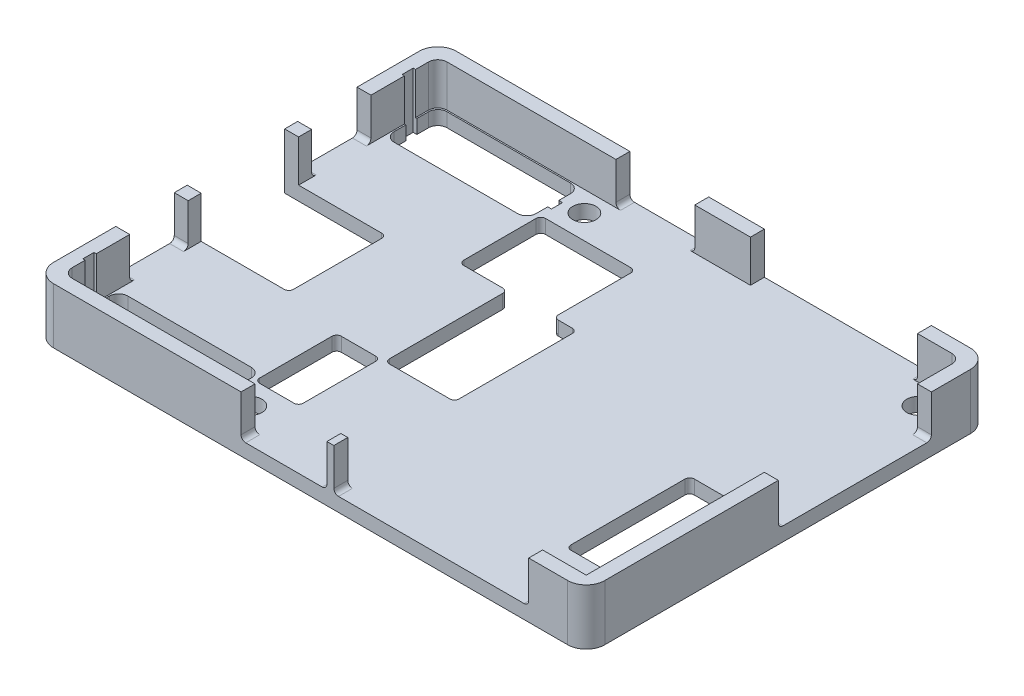
from build123d import *

# Parameters (mm, degrees)
SKETCH_1_W               = 59.4
SKETCH_1_H               = 43.4
EXTRUDE_1_DEPTH          = 6
SKETCH_2_W               = 56.4
SKETCH_2_H               = 40.4
CUT_EXTRUDE_1_DEPTH      = 4.5
SKETCH_3_R               = 1.25
CUT_EXTRUDE_2_DEPTH      = 2.5
SKETCH_4_W               = 10.95
SKETCH_4_H               = 10.5
CUT_EXTRUDE_3_DEPTH      = 5.5
CUT_EXTRUDE_3_DEPTH_BACK = 2.5
SKETCH_5_W               = 6.4
SKETCH_5_H               = 4.5
SKETCH_5_W_2             = 6.3
CUT_EXTRUDE_4_DEPTH      = 4.5
CUT_EXTRUDE_5_DEPTH      = 5.5
CUT_EXTRUDE_5_DEPTH_BACK = 2.5
SKETCH_9_W               = 10.2
SKETCH_9_H               = 8.8
SKETCH_9_W_2             = 4.7
CUT_EXTRUDE_6_DEPTH      = 5.5
CUT_EXTRUDE_6_DEPTH_BACK = 2.5
SKETCH_10_W              = 8
SKETCH_10_H              = 13.3
CUT_EXTRUDE_7_DEPTH      = 5.5
CUT_EXTRUDE_7_DEPTH_BACK = 2.5
FILLET_1_R               = 2
SKETCH_11_W              = 8.5
SKETCH_11_H              = 4.5
SKETCH_11_W_2            = 18
CUT_EXTRUDE_8_DEPTH      = 3
SKETCH_12_W              = 9.25
SKETCH_12_H              = 4.5
SKETCH_12_W_2            = 21
CUT_EXTRUDE_9_DEPTH      = 3
SKETCH_13_W              = 16.5
SKETCH_13_H              = 4.5
CUT_EXTRUDE_10_DEPTH     = 3
SKETCH_14_W              = 7.5
SKETCH_14_H              = 13.2
CUT_EXTRUDE_11_DEPTH     = 10
FILLET_2_R               = 0.5
FILLET_3_R               = 1
FILLET_4_R               = 0.5


with BuildPart() as part:
    # 草图1 → 凸台-拉伸1 (new body)
    with BuildSketch(Plane(origin=(0, 0, 0), x_dir=(1, 0, 0), z_dir=(0, 1, 0))):
        Rectangle(SKETCH_1_W, SKETCH_1_H)
    extrude(amount=EXTRUDE_1_DEPTH)

    # 草图2 → 切除-拉伸1 (cut)
    with BuildSketch(Plane(origin=(0, 6, 0), x_dir=(1, 0, 0), z_dir=(0, 1, 0))):
        Rectangle(SKETCH_2_W, SKETCH_2_H)
    extrude(amount=-CUT_EXTRUDE_1_DEPTH, mode=Mode.SUBTRACT)

    # 草图3 → 切除-拉伸2 (cut, through all)
    with BuildSketch(Plane(origin=(0, 1.5, 0), x_dir=(1, 0, 0), z_dir=(0, 1, 0))):
        with Locations((-10.2, -18)):
            Circle(SKETCH_3_R)
        with Locations((-10.2, 18)):
            Circle(SKETCH_3_R)
        with Locations((25.8, 18)):
            Circle(SKETCH_3_R)
        with Locations((25.8, -18)):
            Circle(SKETCH_3_R)
    extrude(amount=-CUT_EXTRUDE_2_DEPTH, mode=Mode.SUBTRACT)

    # 草图4 → 切除-拉伸3 (cut, two sides)
    with BuildSketch(Plane(origin=(0, 1.5, 0), x_dir=(1, 0, 0), z_dir=(0, 1, 0))) as cut_extrude_3_sk:
        with Locations((-24.225, -0.05)):
            Rectangle(SKETCH_4_W, SKETCH_4_H)
    extrude(amount=CUT_EXTRUDE_3_DEPTH, mode=Mode.SUBTRACT)
    extrude(cut_extrude_3_sk.sketch, amount=-CUT_EXTRUDE_3_DEPTH_BACK, mode=Mode.SUBTRACT)

    # 草图5 → 切除-拉伸4 (cut)
    with BuildSketch(Plane.ZY.offset(29.7)):
        with Locations((-9.8, 3.75)):
            Rectangle(SKETCH_5_W, SKETCH_5_H)
        with Locations((9.85, 3.75)):
            Rectangle(SKETCH_5_W_2, SKETCH_5_H)
    extrude(amount=-CUT_EXTRUDE_4_DEPTH, mode=Mode.SUBTRACT)

    # 草图8 → 切除-拉伸5 (cut, two sides)
    with BuildSketch(Plane(origin=(0, 1.5, 0), x_dir=(1, 0, 0), z_dir=(0, 1, 0))) as cut_extrude_5_sk:
        Polygon((-28.05, 14.35), (-28.05, 16.6), (-28.45, 16.6), (-28.45, 17.8), (-28.05, 17.8), (-28.05, 20.05), (-12.75, 20.05), (-12.75, 17.8), (-12.35, 17.8), (-12.35, 16.6), (-12.75, 16.6), (-12.75, 14.35), align=None)
        Polygon((-28.05, -20.05), (-12.75, -20.05), (-12.75, -17.8), (-12.35, -17.8), (-12.35, -16.6), (-12.75, -16.6), (-12.75, -14.35), (-28.05, -14.35), (-28.05, -16.6), (-28.45, -16.6), (-28.45, -17.8), (-28.05, -17.8), align=None)
    extrude(amount=CUT_EXTRUDE_5_DEPTH, mode=Mode.SUBTRACT)
    extrude(cut_extrude_5_sk.sketch, amount=-CUT_EXTRUDE_5_DEPTH_BACK, mode=Mode.SUBTRACT)

    # 草图9 → 切除-拉伸6 (cut, two sides)
    with BuildSketch(Plane(origin=(0, 1.5, 0), x_dir=(1, 0, 0), z_dir=(0, 1, 0))) as cut_extrude_6_sk:
        with Locations((-7.2, 11)):
            Rectangle(SKETCH_9_W, SKETCH_9_H)
        with Locations((-9.95, -11)):
            Rectangle(SKETCH_9_W_2, SKETCH_9_H)
    extrude(amount=CUT_EXTRUDE_6_DEPTH, mode=Mode.SUBTRACT)
    extrude(cut_extrude_6_sk.sketch, amount=-CUT_EXTRUDE_6_DEPTH_BACK, mode=Mode.SUBTRACT)

    # 草图10 → 切除-拉伸7 (cut, two sides)
    with BuildSketch(Plane(origin=(0, 1.5, 0), x_dir=(1, 0, 0), z_dir=(0, 1, 0))) as cut_extrude_7_sk:
        with Locations((24.05, -7.55)):
            Rectangle(SKETCH_10_W, SKETCH_10_H)
    extrude(amount=CUT_EXTRUDE_7_DEPTH, mode=Mode.SUBTRACT)
    extrude(cut_extrude_7_sk.sketch, amount=-CUT_EXTRUDE_7_DEPTH_BACK, mode=Mode.SUBTRACT)

    # 圆角1
    fillet_1_edges = [part.edges().sort_by_distance(p)[0] for p in [
        (29.7, 3, 21.7),
        (-29.7, 3, 21.7),
        (-29.7, 3, -21.7),
        (29.7, 3, -21.7),
    ]]
    fillet(fillet_1_edges, radius=FILLET_1_R)

    # 草图11 → 切除-拉伸8 (cut)
    with BuildSketch(Plane(origin=(0, 0, -21.7), x_dir=(-1, 0, 0), z_dir=(0, 0, -1))):
        with Locations((4.75, 3.75)):
            Rectangle(SKETCH_11_W, SKETCH_11_H)
        with Locations((-14.5, 3.75)):
            Rectangle(SKETCH_11_W_2, SKETCH_11_H)
    extrude(amount=-CUT_EXTRUDE_8_DEPTH, mode=Mode.SUBTRACT)

    # 草图12 → 切除-拉伸9 (cut)
    with BuildSketch(Plane.XY.offset(21.7)):
        with Locations((-2.875, 3.75)):
            Rectangle(SKETCH_12_W, SKETCH_12_H)
        with Locations((13, 3.75)):
            Rectangle(SKETCH_12_W_2, SKETCH_12_H)
    extrude(amount=-CUT_EXTRUDE_9_DEPTH, mode=Mode.SUBTRACT)

    # 草图13 → 切除-拉伸10 (cut)
    with BuildSketch(Plane(origin=(29.7, 0, 0), x_dir=(0, 0, -1), z_dir=(1, 0, 0))):
        with Locations((7.25, 3.75)):
            Rectangle(SKETCH_13_W, SKETCH_13_H)
    extrude(amount=-CUT_EXTRUDE_10_DEPTH, mode=Mode.SUBTRACT)

    # 草图14 → 切除-拉伸11 (cut)
    with BuildSketch(Plane.XZ):
        with Locations((-3.35, 0)):
            Rectangle(SKETCH_14_W, SKETCH_14_H)
    extrude(amount=-CUT_EXTRUDE_11_DEPTH, mode=Mode.SUBTRACT)

    # 圆角2
    fillet_2_edges = [part.edges().sort_by_distance(p)[0] for p in [
        (-12.3, 0.75, -15.4),
        (-2.1, 0.75, -15.4),
        (-2.1, 0.75, -6.6),
        (-12.3, 0.75, -6.6),
        (-12.3, 0.75, 15.4),
        (-12.3, 0.75, 6.6),
        (-7.6, 0.75, 6.6),
        (-7.6, 0.75, 15.4),
        (28.05, 0.75, 0.9),
        (28.05, 0.75, 14.2),
        (20.05, 0.75, 14.2),
        (20.05, 0.75, 0.9),
        (-7.1, 0.75, -6.6),
        (0.4, 0.75, -6.6),
        (0.4, 0.75, 6.6),
        (-7.1, 0.75, 6.6),
        (-18.75, 0.75, 5.3),
        (-18.75, 0.75, -5.2),
    ]]
    fillet(fillet_2_edges, radius=FILLET_2_R)

    # 圆角3
    fillet_3_edges = [part.edges().sort_by_distance(p)[0] for p in [
        (-28.05, 0.75, 14.35),
        (-12.75, 0.75, 14.35),
        (-12.75, 0.75, 20.05),
        (-28.05, 0.75, 20.05),
        (28.2, 3.75, -20.2),
        (-12.75, 0.75, -20.05),
        (-12.75, 0.75, -14.35),
        (-28.05, 0.75, -14.35),
        (-28.05, 0.75, -20.05),
        (-28.2, 3.75, 20.2),
        (-28.2, 3.75, -20.2),
    ]]
    fillet(fillet_3_edges, radius=FILLET_3_R)

    # 圆角4
    fillet_4_edges = [part.edges().sort_by_distance(p)[0] for p in [
        (23.5, 1.5, -20.95),
        (-9, 1.5, -20.95),
        (-0.5, 1.5, -20.95),
        (23.5, 1.5, 20.95),
        (2.5, 1.5, 20.95),
        (1.75, 1.5, 20.95),
        (-7.5, 1.5, 20.95),
        (28.95, 1.5, 1),
        (28.95, 1.5, -15.5),
        (-28.95, 1.5, -6.6),
        (-28.95, 1.5, -13),
        (-28.95, 1.5, 13),
        (-28.95, 1.5, 6.7),
    ]]
    fillet(fillet_4_edges, radius=FILLET_4_R)


solid = part.part
